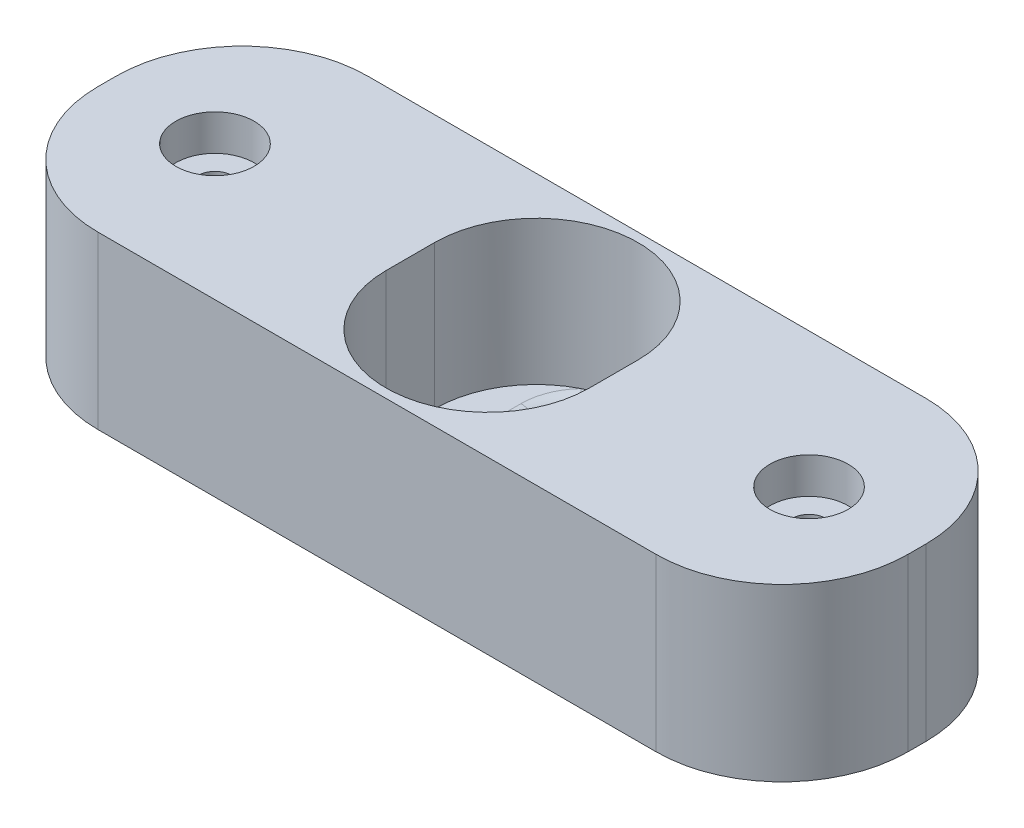
from build123d import *

# Parameters (mm, degrees)
SKETCH1_W           = 45
SKETCH1_H           = 15
BOSS_EXTRUDE1_DEPTH = 9.5
SKETCH2_R           = 5.5
CUT_EXTRUDE1_DEPTH  = 8
CUT_EXTRUDE6_DEPTH  = 8
CUT_EXTRUDE2_REACH  = 3.5
SKETCH4_R           = 2.175
CUT_EXTRUDE3_DEPTH  = 2
FILLET1_R           = 7
SKETCH5_R           = 2.05
CUT_EXTRUDE4_DEPTH  = 5
SKETCH6_R           = 0.95
CUT_EXTRUDE5_DEPTH  = 3
FILLET3_R           = 1


with BuildPart() as part:
    # Sketch1 → Boss-Extrude1 (new body)
    with BuildSketch(Plane(origin=(0, 0, 0), x_dir=(1, 0, 0), z_dir=(0, 1, 0))):
        with Locations((22.5, 7.5)):
            Rectangle(SKETCH1_W, SKETCH1_H)
    extrude(amount=-BOSS_EXTRUDE1_DEPTH)

    # Sketch2 → Cut-Extrude1 (cut)
    with BuildSketch(Plane(origin=(0, 0, 0), x_dir=(1, 0, 0), z_dir=(0, 1, 0))):
        with Locations((22.5, 8.82)):
            Circle(SKETCH2_R)
    extrude(amount=-CUT_EXTRUDE1_DEPTH, mode=Mode.SUBTRACT)

    # Sketch8 → Cut-Extrude6 (cut)
    with BuildSketch(Plane(origin=(0, 0, 0), x_dir=(1, 0, 0), z_dir=(0, 1, 0))):
        with BuildLine():
            Line((16.85, 8.85), (16.85, 6.15))
            ThreePointArc((16.85, 6.15), (22.5, 0.5), (28.15, 6.15))
            Line((28.15, 6.15), (28.15, 8.85))
            ThreePointArc((28.15, 8.85), (22.5, 14.5), (16.85, 8.85))
        make_face()
    extrude(amount=-CUT_EXTRUDE6_DEPTH, mode=Mode.SUBTRACT)

    # Sketch3 → Cut-Extrude2 (cut, up to next)
    with BuildSketch(Plane(origin=(0, -8, 0), x_dir=(1, 0, 0), z_dir=(0, 1, 0)), mode=Mode.PRIVATE) as cut_extrude2_sk1:
        with BuildLine():
            Line((20, 11.5), (20, 3.5))
            ThreePointArc((20, 3.5), (22.5, 1), (25, 3.5))
            Line((25, 3.5), (25, 11.5))
            ThreePointArc((25, 11.5), (22.5, 14), (20, 11.5))
        make_face()
    cut_extrude2_tool1 = extrude(cut_extrude2_sk1.sketch, amount=-CUT_EXTRUDE2_REACH, mode=Mode.PRIVATE) & part.part
    add(cut_extrude2_tool1.solids().sort_by_distance((22.5, -8, -7.5))[0], mode=Mode.SUBTRACT)

    # Sketch4 → Cut-Extrude3 (cut)
    with BuildSketch(Plane(origin=(0, 0, 0), x_dir=(1, 0, 0), z_dir=(0, 1, 0))):
        with Locations((6, 7.5)):
            Circle(SKETCH4_R)
        with Locations((39, 7.5)):
            Circle(SKETCH4_R)
    extrude(amount=-CUT_EXTRUDE3_DEPTH, mode=Mode.SUBTRACT)

    # Fillet1
    fillet1_edges = [part.edges().sort_by_distance(p)[0] for p in [
        (0, -4.75, -15),
        (45, -4.75, -15),
        (45, -4.75, 0),
        (0, -4.75, 0),
    ]]
    fillet(fillet1_edges, radius=FILLET1_R)

    # Sketch5 → Cut-Extrude4 (cut)
    with BuildSketch(Plane(origin=(0, -9.5, 0), x_dir=(-1, 0, 0), z_dir=(0, -1, 0))):
        with Locations((-39, 7.5)):
            Circle(SKETCH5_R)
        with Locations((-6, 7.5)):
            Circle(SKETCH5_R)
    extrude(amount=-CUT_EXTRUDE4_DEPTH, mode=Mode.SUBTRACT)

    # Sketch6 → Cut-Extrude5 (cut)
    with BuildSketch(Plane(origin=(0, -2, 0), x_dir=(1, 0, 0), z_dir=(0, 1, 0))):
        with Locations((6, 7.5)):
            Circle(SKETCH6_R)
        with Locations((39, 7.5)):
            Circle(SKETCH6_R)
    extrude(amount=-CUT_EXTRUDE5_DEPTH, mode=Mode.SUBTRACT)

    # Fillet3
    fillet3_edges = [part.edges().sort_by_distance(p)[0] for p in [
        (22.5, -8, -14),
        (20, -8, -7.5),
        (22.5, -8, -1),
        (25, -8, -7.5),
    ]]
    fillet(fillet3_edges, radius=FILLET3_R)


solid = part.part
